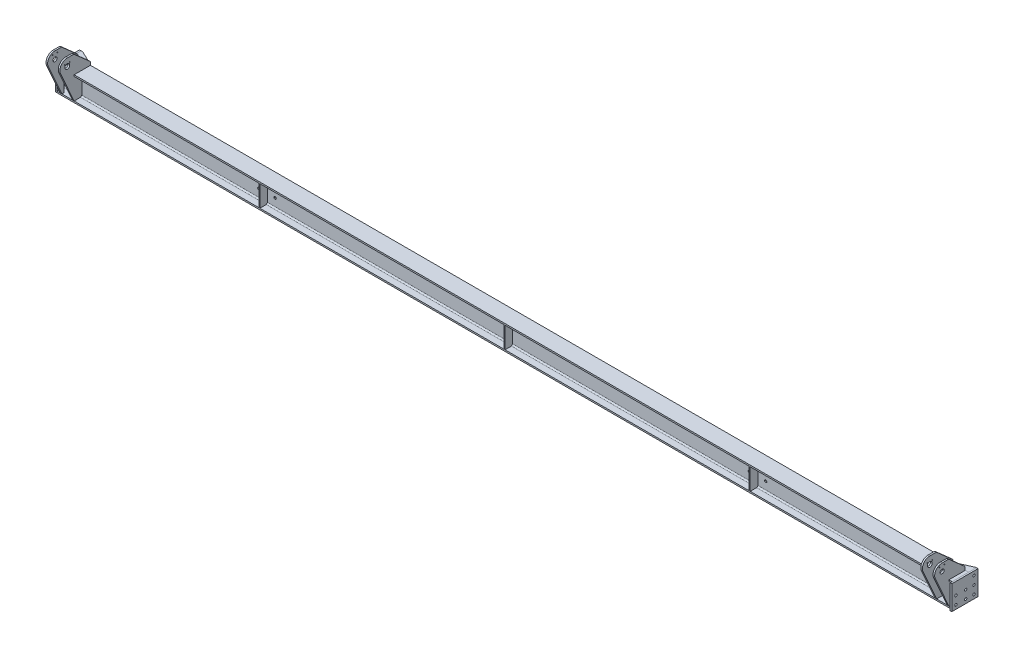
from build123d import *

# Parameters (mm, degrees)
H_HM150_100_1_DEPTH = 5495
SKETCH_12_W         = 20
SKETCH_12_H         = 100
CUT_EXTRUDE_1_DEPTH = 148.000003
SKETCH_13_W         = 148
SKETCH_13_H         = 148
EXTRUDE_1_DEPTH     = 10
EXTRUDE_2_DEPTH     = 6
EXTRUDE_3_DEPTH     = 6
SKETCH_16_W         = 160
SKETCH_16_H         = 148
EXTRUDE_4_DEPTH     = 10
EXTRUDE_5_DEPTH     = 6
EXTRUDE_6_DEPTH     = 6
SKETCH_20_R         = 7
CUT_EXTRUDE_2_DEPTH = 10
SKETCH_21_R         = 7
CUT_EXTRUDE_3_DEPTH = 10
SKETCH_22_R         = 7
CUT_EXTRUDE_4_DEPTH = 6
EXTRUDE_7_DEPTH     = 6
EXTRUDE_8_DEPTH     = 6
EXTRUDE_9_DEPTH     = 3
EXTRUDE_10_DEPTH    = 10
SKETCH_28_R         = 12.5
CUT_EXTRUDE_5_DEPTH = 10
EXTRUDE_11_DEPTH    = 10
SKETCH_30_R         = 15
CUT_EXTRUDE_6_DEPTH = 10
CUT_EXTRUDE_7_DEPTH = 10
SKETCH_32_W         = 2.5
SKETCH_32_H         = 10.001
M6X1_0_1_AT_2_COUNT = 2
M6X1_0_1_AT_2_PITCH = 30
SKETCH_33_W         = 2.5
SKETCH_33_H         = 10.001
M6X1_0_2_AT_2_COUNT = 2
M6X1_0_2_AT_2_PITCH = 30


with BuildPart() as part:
    # 草图11 → H型钢 HM150×100(1) (new body)
    with BuildSketch(Plane(origin=(4989.658786023, -1451.963997136, -50), x_dir=(0, 0, 1), z_dir=(-1, 0, 0))):
        with BuildLine():
            Line((-50, -74), (50, -74))
            Line((50, -74), (50, -65))
            Line((50, -65), (11, -65))
            ThreePointArc((11, -65), (5.343145751, -62.656854249), (3, -57))
            Line((3, -57), (3, 57))
            ThreePointArc((3, 57), (5.343145751, 62.656854249), (11, 65))
            Line((11, 65), (50, 65))
            Line((50, 65), (50, 74))
            Line((50, 74), (-50, 74))
            Line((-50, 74), (-50, 65))
            Line((-50, 65), (-11, 65))
            ThreePointArc((-11, 65), (-5.343145751, 62.656854249), (-3, 57))
            Line((-3, 57), (-3, -57))
            ThreePointArc((-3, -57), (-5.343145751, -62.656854249), (-11, -65))
            Line((-11, -65), (-50, -65))
            Line((-50, -65), (-50, -74))
        make_face()
    extrude(amount=H_HM150_100_1_DEPTH)

    # 草图12 → 切除-拉伸1 (cut)
    with BuildSketch(Plane(origin=(0, -1377.963997136, 0), x_dir=(-1, 0, 0), z_dir=(0, 1, 0))):
        with Locations((495.341213977, -50)):
            Rectangle(SKETCH_12_W, SKETCH_12_H)
    extrude(amount=-CUT_EXTRUDE_1_DEPTH, mode=Mode.SUBTRACT)

    # 草图22 → 切除-拉伸4 (cut)
    with BuildSketch(Plane.XY.offset(-47)):
        with Locations((3702.158786023, -1412.963997136)):
            Circle(SKETCH_22_R)
        with Locations((3802.158786023, -1412.963997136)):
            Circle(SKETCH_22_R)
        with Locations((3702.158786023, -1462.963997136)):
            Circle(SKETCH_22_R)
        with Locations((3802.158786023, -1462.963997136)):
            Circle(SKETCH_22_R)
        with Locations((702.158786023, -1412.963997136)):
            Circle(SKETCH_22_R)
        with Locations((802.158786023, -1412.963997136)):
            Circle(SKETCH_22_R)
        with Locations((702.158786023, -1462.963997136)):
            Circle(SKETCH_22_R)
        with Locations((802.158786023, -1462.963997136)):
            Circle(SKETCH_22_R)
    extrude(amount=-CUT_EXTRUDE_4_DEPTH, mode=Mode.SUBTRACT)


with BuildPart() as body_2:
    # 草图13 → 凸台-拉伸1 (new body)
    with BuildSketch(Plane.ZY.offset(485.341213977)):
        with Locations((-74, -1451.963997136)):
            Rectangle(SKETCH_13_W, SKETCH_13_H)
    extrude(amount=EXTRUDE_1_DEPTH)

    # 草图20 → 切除-拉伸2 (cut)
    with BuildSketch(Plane.ZY.offset(495.341213977)):
        with Locations(Location((-123, -1401.963997136, 0), (0, 0, 270))):
            Circle(SKETCH_20_R)
        with Locations(Location((-25, -1401.963997136, 0), (0, 0, 270))):
            Circle(SKETCH_20_R)
        with Locations(Location((-123, -1451.963997136, 0), (0, 0, 270))):
            Circle(SKETCH_20_R)
        with Locations(Location((-25, -1451.963997136, 0), (0, 0, 270))):
            Circle(SKETCH_20_R)
        with Locations(Location((-123, -1501.963997136, 0), (0, 0, 270))):
            Circle(SKETCH_20_R)
        with Locations(Location((-25, -1501.963997136, 0), (0, 0, 270))):
            Circle(SKETCH_20_R)
    extrude(amount=-CUT_EXTRUDE_2_DEPTH, mode=Mode.SUBTRACT)


with BuildPart() as body_3:
    # 草图14 → 凸台-拉伸2 (new body)
    with BuildSketch(Plane(origin=(0, -1377.963997136, 4.174981402), x_dir=(1, 0, 0), z_dir=(0, 1, 0))):
        Polygon((-485.341213977, 152.174981402), (-485.341213977, 104.174981402), (-385.341213977, 104.174981402), (-385.341213977, 109.174981402), (-476.160159048, 152.174981402), align=None)
    extrude(amount=-EXTRUDE_2_DEPTH)


with BuildPart() as body_4:
    # 草图15 → 凸台-拉伸3 (new body)
    with BuildSketch(Plane(origin=(0, -1525.963997136, 0), x_dir=(-1, 0, 0), z_dir=(0, -1, 0))):
        Polygon((485.341213977, 148), (476.160159048, 148), (385.341213977, 105), (385.341213977, 100), (485.341213977, 100), align=None)
    extrude(amount=-EXTRUDE_3_DEPTH)


with BuildPart() as body_5:
    # 草图16 → 凸台-拉伸4 (new body)
    with BuildSketch(Plane(origin=(4989.658786023, 0, 0), x_dir=(0, 0, -1), z_dir=(1, 0, 0))):
        with Locations((68, -1451.963997136)):
            Rectangle(SKETCH_16_W, SKETCH_16_H)
    extrude(amount=EXTRUDE_4_DEPTH)

    # 草图21 → 切除-拉伸3 (cut)
    with BuildSketch(Plane(origin=(4999.658786023, 0, 0), x_dir=(0, 0, -1), z_dir=(1, 0, 0))):
        with Locations(Location((123, -1401.963997136, 0), (0, 0, 90))):
            Circle(SKETCH_21_R)
        with Locations(Location((123, -1451.963997136, 0), (0, 0, 90))):
            Circle(SKETCH_21_R)
        with Locations(Location((13, -1451.963997136, 0), (0, 0, 90))):
            Circle(SKETCH_21_R)
        with Locations(Location((13, -1501.963997136, 0), (0, 0, 90))):
            Circle(SKETCH_21_R)
        with Locations(Location((123, -1501.963997136, 0), (0, 0, 90))):
            Circle(SKETCH_21_R)
        with Locations(Location((73, -1501.963997136, 0), (0, 0, 90))):
            Circle(SKETCH_21_R)
        with Locations(Location((73, -1451.963997136, 0), (0, 0, 90))):
            Circle(SKETCH_21_R)
    extrude(amount=-CUT_EXTRUDE_3_DEPTH, mode=Mode.SUBTRACT)


with BuildPart() as body_6:
    # 草图17 → 凸台-拉伸5 (new body)
    with BuildSketch(Plane(origin=(0, -1377.963997136, 0), x_dir=(-1, 0, 0), z_dir=(0, 1, 0))):
        Polygon((-4989.658786023, -148), (-4984.658786023, -148), (-4889.658786023, -105), (-4889.658786023, -100), (-4989.658786023, -100), align=None)
    extrude(amount=-EXTRUDE_5_DEPTH)


with BuildPart() as body_7:
    # 草图18 → 凸台-拉伸6 (new body)
    with BuildSketch(Plane(origin=(0, -1525.963997136, 0), x_dir=(-1, 0, 0), z_dir=(0, -1, 0))):
        Polygon((-4989.658786023, 148), (-4989.658786023, 100), (-4889.658786023, 100), (-4889.658786023, 105), (-4984.658786023, 148), align=None)
    extrude(amount=-EXTRUDE_6_DEPTH)


with BuildPart() as body_8:
    # 草图24 → 凸台-拉伸7 (new body)
    with BuildSketch(Plane(origin=(749.658786023, 0, 0), x_dir=(0, 0, -1), z_dir=(1, 0, 0))):
        Polygon((47, -1394.963997136), (47, -1508.963997136), (39, -1516.963997136), (0, -1516.963997136), (0, -1386.963997136), (39, -1386.963997136), align=None)
    extrude(amount=EXTRUDE_7_DEPTH)


with BuildPart() as body_9:
    # 草图25 → 凸台-拉伸8 (new body)
    with BuildSketch(Plane.ZY.offset(-3754.658786023)):
        with BuildLine():
            Line((-47, -1394.963997136), (-47, -1508.963997136))
            ThreePointArc((-47, -1508.963997136), (-44.656854249, -1514.620851386), (-39, -1516.963997136))
            Line((-39, -1516.963997136), (0, -1516.963997136))
            Line((0, -1516.963997136), (0, -1386.963997136))
            Line((0, -1386.963997136), (-39, -1386.963997136))
            ThreePointArc((-39, -1386.963997136), (-44.656854249, -1389.307142887), (-47, -1394.963997136))
        make_face()
    extrude(amount=EXTRUDE_8_DEPTH)


with BuildPart() as body_10:
    # 草图26 → 凸台-拉伸9 (new, symmetric)
    with BuildSketch(Plane(origin=(2252.158786023, 0, 0), x_dir=(0, 0, -1), z_dir=(1, 0, 0))):
        Polygon((39, -1516.963997136), (47, -1508.963997136), (47, -1394.963997136), (39, -1386.963997136), (0, -1386.963997136), (0, -1516.963997136), align=None)
    extrude(amount=EXTRUDE_9_DEPTH, both=True)


with BuildPart() as body_11:
    # 草图27 → 凸台-拉伸10 (new body)
    with BuildSketch(Plane(origin=(4969.658786023, 0, 0), x_dir=(0, 0, -1), z_dir=(1, 0, 0))):
        with BuildLine():
            Line((39, -1386.963997136), (0, -1386.963997136))
            Line((0, -1386.963997136), (0, -1377.963997136))
            Line((0, -1377.963997136), (100, -1377.963997136))
            Line((100, -1377.963997136), (100, -1362.476684252))
            ThreePointArc((100, -1362.476684252), (99.114882438, -1358.363422998), (96.616216371, -1354.978305699))
            Line((96.616216371, -1354.978305699), (0.835170973, -1270.465618583))
            ThreePointArc((0.835170973, -1270.465618583), (-2.244365143, -1268.610287029), (-5.781045398, -1267.963997136))
            Line((-5.781045398, -1267.963997136), (-42, -1267.963997136))
            ThreePointArc((-42, -1267.963997136), (-79.763933252, -1288.491863079), (-83.073957203, -1331.346870678))
            Line((-83.073957203, -1331.346870678), (0, -1516.963997136))
            Line((0, -1516.963997136), (39, -1516.963997136))
            Line((39, -1516.963997136), (47, -1508.963997136))
            Line((47, -1508.963997136), (47, -1394.963997136))
            Line((47, -1394.963997136), (39, -1386.963997136))
        make_face()
    extrude(amount=-EXTRUDE_10_DEPTH)

    # 草图28 → 切除-拉伸5 (cut)
    with BuildSketch(Plane.ZY.offset(-4959.658786023)):
        with Locations(Location((42, -1312.963997136, 0), (0, 0, 270))):
            Circle(SKETCH_28_R)
    extrude(amount=-CUT_EXTRUDE_5_DEPTH, mode=Mode.SUBTRACT)

    # 草图31 → 切除-拉伸7 (cut)
    with BuildSketch(Plane.ZY.offset(-4959.658786023)):
        Polygon((-12, -1516.963997136), (-12, -1386.963997136), (-39, -1386.963997136), (-47, -1394.963997136), (-47, -1508.963997136), (-39, -1516.963997136), align=None)
    extrude(amount=-CUT_EXTRUDE_7_DEPTH, mode=Mode.SUBTRACT)

    # 草图33 → M6x1.0 螺纹孔2 (revolve, cut)
    with BuildSketch(Plane(origin=(4969.658786023, -1283.144511847, 57), x_dir=(0, 0, -1), z_dir=(0, 1, 0))):
        with Locations((1.25, 5.0005)):
            Rectangle(SKETCH_33_W, SKETCH_33_H)
    m6x1_0_2 = revolve(axis=Axis((4976.008786023, -1283.144511847, 57), (-1, 0, 0)), mode=Mode.SUBTRACT)

    # M6x1.0 螺纹孔2 at 2: M6x1.0 螺纹孔2 ×2
    with Locations(*[Vector(0, 0.01218182341047067, -0.9999257988362917) * (i * M6X1_0_2_AT_2_PITCH) for i in range(1, M6X1_0_2_AT_2_COUNT)]):
        add(m6x1_0_2, mode=Mode.SUBTRACT)


with BuildPart() as body_12:
    # 草图29 → 凸台-拉伸11 (new body)
    with BuildSketch(Plane.ZY.offset(-4894.658786023)):
        with BuildLine():
            Line((-39, -1386.963997136), (-47, -1394.963997136))
            Line((-47, -1394.963997136), (-47, -1508.963997136))
            Line((-47, -1508.963997136), (-39, -1516.963997136))
            Line((-39, -1516.963997136), (0, -1516.963997136))
            Line((0, -1516.963997136), (83.073957203, -1331.346870678))
            ThreePointArc((83.073957203, -1331.346870678), (79.763933252, -1288.491863079), (42, -1267.963997136))
            Line((42, -1267.963997136), (5.781045398, -1267.963997136))
            ThreePointArc((5.781045398, -1267.963997136), (2.244365143, -1268.610287029), (-0.835170973, -1270.465618583))
            Line((-0.835170973, -1270.465618583), (-96.616216371, -1354.978305699))
            ThreePointArc((-96.616216371, -1354.978305699), (-99.114882438, -1358.363422998), (-100, -1362.476684252))
            Line((-100, -1362.476684252), (-100, -1377.963997136))
            Line((-100, -1377.963997136), (0, -1377.963997136))
            Line((0, -1377.963997136), (0, -1386.963997136))
            Line((0, -1386.963997136), (-39, -1386.963997136))
        make_face()
    extrude(amount=EXTRUDE_11_DEPTH)

    # 草图30 → 切除-拉伸6 (cut)
    with BuildSketch(Plane.ZY.offset(-4884.658786023)):
        with Locations(Location((42, -1312.963997136, 0), (0, 0, 270))):
            Circle(SKETCH_30_R)
    extrude(amount=-CUT_EXTRUDE_6_DEPTH, mode=Mode.SUBTRACT)

    # 草图32 → M6x1.0 螺纹孔1 (revolve, cut)
    with BuildSketch(Plane(origin=(4884.658786023, -1298.076751783, 27), x_dir=(0, 0, 1), z_dir=(0, 1, 0))):
        with Locations((1.25, 5.0005)):
            Rectangle(SKETCH_32_W, SKETCH_32_H)
    m6x1_0_1 = revolve(axis=Axis((4878.308786023, -1298.076751783, 27), (1, 0, 0)), mode=Mode.SUBTRACT)

    # M6x1.0 螺纹孔1 at 2: M6x1.0 螺纹孔1 ×2
    with Locations(*[Vector(0, 0.007545228127089054, 0.9999715343611089) * (i * M6X1_0_1_AT_2_PITCH) for i in range(1, M6X1_0_1_AT_2_COUNT)]):
        add(m6x1_0_1, mode=Mode.SUBTRACT)


with BuildPart() as body_13:
    # 镜向1: mirrored copy
    add(body_11.part.mirror(Plane(origin=(2252.158786023, 0, 0), x_dir=(0, 0, 1), z_dir=(1, 0, 0))))


with BuildPart() as body_14:
    # Mirror 1 2: mirrored copy
    add(body_12.part.mirror(Plane(origin=(2252.158786023, 0, 0), x_dir=(0, 0, 1), z_dir=(1, 0, 0))))


solid = Compound([part.part, body_2.part, body_3.part, body_4.part, body_5.part, body_6.part, body_7.part, body_8.part, body_9.part, body_10.part, body_11.part, body_12.part, body_13.part, body_14.part])
